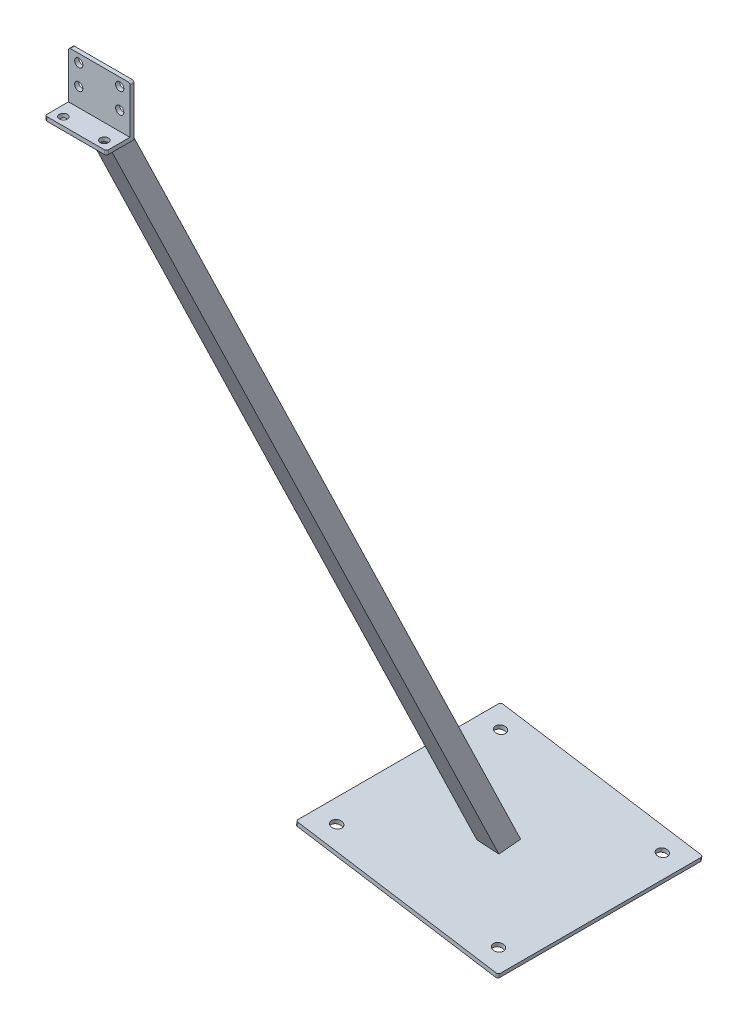
from build123d import *

# Parameters (mm, degrees)
BOSS_EXTRUDE1_DEPTH      = 60
SKETCH3_W                = 20
SKETCH3_H                = 20
SKETCH3_W_2              = 18
SKETCH3_H_2              = 18
BOSS_EXTRUDE2_DEPTH      = 2000
BOSS_EXTRUDE2_DEPTH_BACK = 20
CUT_EXTRUDE1_DEPTH       = 60
SKETCH7_W                = 200
SKETCH7_H                = 200
BOSS_EXTRUDE3_DEPTH      = 4
SKETCH8_W                = 109.20231627
SKETCH8_H                = 482.966945154
CUT_EXTRUDE3_DEPTH       = 1000
CUT_EXTRUDE4_REACH       = 29
SKETCH9_R                = 3.999999996
CUT_EXTRUDE5_REACH       = 52
SKETCH10_R               = 4.000000003
CUT_EXTRUDE6_REACH       = 1055.099
SKETCH11_R               = 5
FILLET1_R                = 2
FILLET2_R                = 2


with BuildPart() as part:
    # Sketch1 → Boss-Extrude1 (new body)
    with BuildSketch(Plane(origin=(0, 0, 0), x_dir=(0, 0, -1), z_dir=(1, 0, 0))):
        Polygon((0, 0), (0, 50), (-4, 50), (-4, 4), (-27, 4), (-27, 0), align=None)
    extrude(amount=BOSS_EXTRUDE1_DEPTH)

    # Sketch3 → Boss-Extrude2 (add, two sides)
    with BuildSketch(Plane(origin=(0.734152256, 4.01424851, 2.317627458), x_dir=(0, -0.5, 0.866025404), z_dir=(-0.156434465, -0.855363194, -0.49384417))) as boss_extrude2_sk:
        with Locations((0, -29.630650218)):
            Rectangle(SKETCH3_W, SKETCH3_H)
        with Locations((0, -29.630650218)):
            Rectangle(SKETCH3_W_2, SKETCH3_H_2, mode=Mode.SUBTRACT)
    extrude(amount=BOSS_EXTRUDE2_DEPTH)
    extrude(boss_extrude2_sk.sketch, amount=-BOSS_EXTRUDE2_DEPTH_BACK)

    # Sketch5 → Cut-Extrude1 (cut)
    with BuildSketch(Plane.ZY):
        Polygon((4, 4), (4, 36.054903459), (38.781358344, 4), align=None)
    extrude(amount=-CUT_EXTRUDE1_DEPTH, mode=Mode.SUBTRACT)

    # Sketch7 → Boss-Extrude3 (add)
    with BuildSketch(Plane(origin=(-155.547262091, -982.086761679, 2e-09), x_dir=(0.987688341, -0.156434465, 0), z_dir=(0.156434465, 0.987688341, 0))):
        with Locations((5.477031178, 566.441418592)):
            Rectangle(SKETCH7_W, SKETCH7_H)
    extrude(amount=BOSS_EXTRUDE3_DEPTH)

    # Sketch8 → Cut-Extrude3 (cut)
    with BuildSketch(Plane(origin=(-155.547262091, -982.086761679, 2e-09), x_dir=(0.987688341, -0.156434465, 0), z_dir=(-0.156434465, -0.987688341, 0))):
        with Locations((4.33544583, -787.065663544)):
            Rectangle(SKETCH8_W, SKETCH8_H)
    extrude(amount=CUT_EXTRUDE3_DEPTH, mode=Mode.SUBTRACT)

    # Sketch9 → Cut-Extrude4 (cut, up to next)
    with BuildSketch(Plane(origin=(0, 0, 0), x_dir=(-1, 0, 0), z_dir=(0, 0, -1)), mode=Mode.PRIVATE) as cut_extrude4_sk1:
        with Locations((-50, 22)):
            Circle(SKETCH9_R)
    cut_extrude4_tool1 = extrude(cut_extrude4_sk1.sketch, amount=-CUT_EXTRUDE4_REACH, mode=Mode.PRIVATE) & part.part
    add(cut_extrude4_tool1.solids().sort_by_distance((50, 22, 0))[0], mode=Mode.SUBTRACT)
    # Sketch9 → Cut-Extrude4 (cut, up to next)
    with BuildSketch(Plane(origin=(0, 0, 0), x_dir=(-1, 0, 0), z_dir=(0, 0, -1)), mode=Mode.PRIVATE) as cut_extrude4_sk2:
        with Locations((-10, 22)):
            Circle(SKETCH9_R)
    cut_extrude4_tool2 = extrude(cut_extrude4_sk2.sketch, amount=-CUT_EXTRUDE4_REACH, mode=Mode.PRIVATE) & part.part
    add(cut_extrude4_tool2.solids().sort_by_distance((10, 22, 0))[0], mode=Mode.SUBTRACT)
    # Sketch9 → Cut-Extrude4 (cut, up to next)
    with BuildSketch(Plane(origin=(0, 0, 0), x_dir=(-1, 0, 0), z_dir=(0, 0, -1)), mode=Mode.PRIVATE) as cut_extrude4_sk3:
        with Locations((-10, 42)):
            Circle(SKETCH9_R)
    cut_extrude4_tool3 = extrude(cut_extrude4_sk3.sketch, amount=-CUT_EXTRUDE4_REACH, mode=Mode.PRIVATE) & part.part
    add(cut_extrude4_tool3.solids().sort_by_distance((10, 42, 0))[0], mode=Mode.SUBTRACT)
    # Sketch9 → Cut-Extrude4 (cut, up to next)
    with BuildSketch(Plane(origin=(0, 0, 0), x_dir=(-1, 0, 0), z_dir=(0, 0, -1)), mode=Mode.PRIVATE) as cut_extrude4_sk4:
        with Locations((-50, 42)):
            Circle(SKETCH9_R)
    cut_extrude4_tool4 = extrude(cut_extrude4_sk4.sketch, amount=-CUT_EXTRUDE4_REACH, mode=Mode.PRIVATE) & part.part
    add(cut_extrude4_tool4.solids().sort_by_distance((50, 42, 0))[0], mode=Mode.SUBTRACT)

    # Sketch10 → Cut-Extrude5 (cut, up to next)
    with BuildSketch(Plane.XZ, mode=Mode.PRIVATE) as cut_extrude5_sk1:
        with Locations((50, 19)):
            Circle(SKETCH10_R)
    cut_extrude5_tool1 = extrude(cut_extrude5_sk1.sketch, amount=-CUT_EXTRUDE5_REACH, mode=Mode.PRIVATE) & part.part
    add(cut_extrude5_tool1.solids().sort_by_distance((50, 0, 19))[0], mode=Mode.SUBTRACT)
    # Sketch10 → Cut-Extrude5 (cut, up to next)
    with BuildSketch(Plane.XZ, mode=Mode.PRIVATE) as cut_extrude5_sk2:
        with Locations((10, 19)):
            Circle(SKETCH10_R)
    cut_extrude5_tool2 = extrude(cut_extrude5_sk2.sketch, amount=-CUT_EXTRUDE5_REACH, mode=Mode.PRIVATE) & part.part
    add(cut_extrude5_tool2.solids().sort_by_distance((10, 0, 19))[0], mode=Mode.SUBTRACT)

    # Sketch11 → Cut-Extrude6 (cut, up to next)
    with BuildSketch(Plane(origin=(-155.547262091, -982.086761679, 2e-09), x_dir=(0.987688341, -0.156434465, 0), z_dir=(-0.156434465, -0.987688341, 0)), mode=Mode.PRIVATE) as cut_extrude6_sk1:
        with Locations((-74.522968646, -486.441418617)):
            Circle(SKETCH11_R)
    cut_extrude6_tool1 = extrude(cut_extrude6_sk1.sketch, amount=-CUT_EXTRUDE6_REACH, mode=Mode.PRIVATE) & part.part
    add(cut_extrude6_tool1.solids().sort_by_distance((-229.152729, -970.428801, -486.441419))[0], mode=Mode.SUBTRACT)
    # Sketch11 → Cut-Extrude6 (cut, up to next)
    with BuildSketch(Plane(origin=(-155.547262091, -982.086761679, 2e-09), x_dir=(0.987688341, -0.156434465, 0), z_dir=(-0.156434465, -0.987688341, 0)), mode=Mode.PRIVATE) as cut_extrude6_sk2:
        with Locations((85.477031354, -486.441418617)):
            Circle(SKETCH11_R)
    cut_extrude6_tool2 = extrude(cut_extrude6_sk2.sketch, amount=-CUT_EXTRUDE6_REACH, mode=Mode.PRIVATE) & part.part
    add(cut_extrude6_tool2.solids().sort_by_distance((-71.122595, -995.458315, -486.441419))[0], mode=Mode.SUBTRACT)
    # Sketch11 → Cut-Extrude6 (cut, up to next)
    with BuildSketch(Plane(origin=(-155.547262091, -982.086761679, 2e-09), x_dir=(0.987688341, -0.156434465, 0), z_dir=(-0.156434465, -0.987688341, 0)), mode=Mode.PRIVATE) as cut_extrude6_sk3:
        with Locations((85.477031354, -646.441418617)):
            Circle(SKETCH11_R)
    cut_extrude6_tool3 = extrude(cut_extrude6_sk3.sketch, amount=-CUT_EXTRUDE6_REACH, mode=Mode.PRIVATE) & part.part
    add(cut_extrude6_tool3.solids().sort_by_distance((-71.122595, -995.458315, -646.441419))[0], mode=Mode.SUBTRACT)
    # Sketch11 → Cut-Extrude6 (cut, up to next)
    with BuildSketch(Plane(origin=(-155.547262091, -982.086761679, 2e-09), x_dir=(0.987688341, -0.156434465, 0), z_dir=(-0.156434465, -0.987688341, 0)), mode=Mode.PRIVATE) as cut_extrude6_sk4:
        with Locations((-74.522968646, -646.441418617)):
            Circle(SKETCH11_R)
    cut_extrude6_tool4 = extrude(cut_extrude6_sk4.sketch, amount=-CUT_EXTRUDE6_REACH, mode=Mode.PRIVATE) & part.part
    add(cut_extrude6_tool4.solids().sort_by_distance((-229.152729, -970.428801, -646.441419))[0], mode=Mode.SUBTRACT)

    # Fillet1
    fillet1_edges = [part.edges().sort_by_distance(p)[0] for p in [
        (60, 50, 2),
        (60, 2, 27),
        (0, 2, 27),
        (0, 50, 2),
    ]]
    fillet(fillet1_edges, radius=FILLET1_R)

    # Fillet2
    fillet2_edges = [part.edges().sort_by_distance(p)[0] for p in [
        (-248.593627385, -965.324734939, -666.44141859),
        (-248.593627385, -965.324734938, -466.44141859),
        (-51.055959266, -996.611627945, -466.44141859),
        (-51.055959266, -996.611627945, -666.44141859),
    ]]
    fillet(fillet2_edges, radius=FILLET2_R)


solid = part.part
